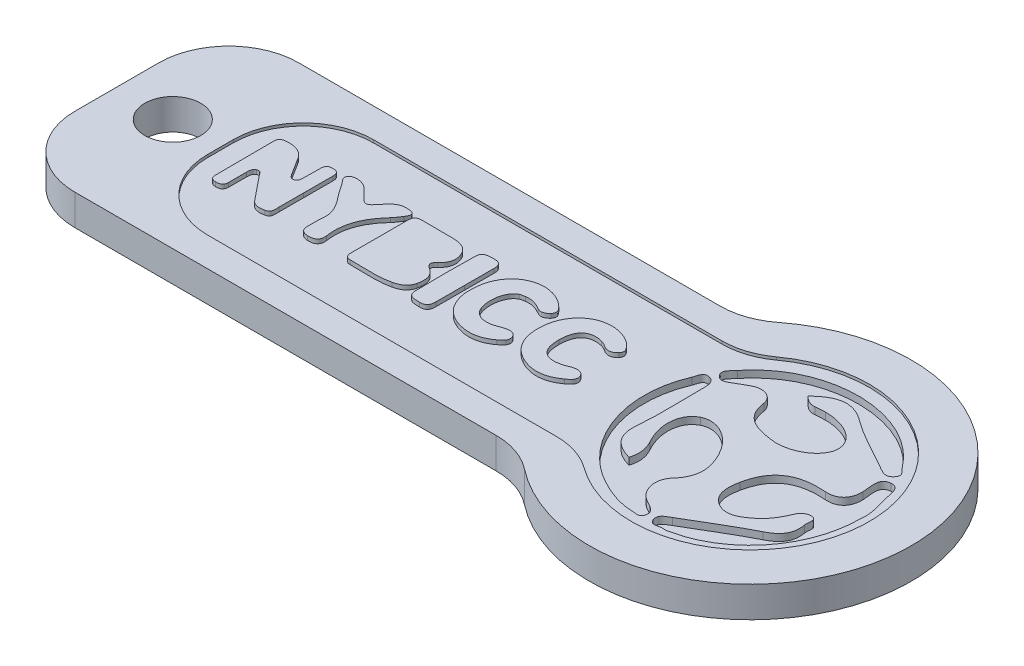
from build123d import *

# Parameters (mm, degrees)
ESQUISSE1_R             = 2
BOSS_EXTRU_1_DEPTH      = 2
ESQUISSE3_R             = 2
BOSS_EXTRU_2_DEPTH      = 0.2
CONG_1_R                = 5
BOSS_EXTRU_3_DEPTH      = 0.3
ENL_V_MAT_EXTRU_1_DEPTH = 0.5


with BuildPart() as part:
    # Esquisse1 → Boss.-Extru.1 (new body)
    with BuildSketch(Plane(origin=(0, 0, 0), x_dir=(1, 0, 0), z_dir=(0, 1, 0))):
        with BuildLine():
            Line((-18.5, 8), (18.5, 8))
            ThreePointArc((18.5, 8), (38.261355821, 0), (18.5, -8))
            Line((18.5, -8), (-18.5, -8))
            Line((-18.5, -8), (-18.5, 8))
        make_face()
        with Locations((-14.5, 0)):
            Circle(ESQUISSE1_R, mode=Mode.SUBTRACT)
    extrude(amount=BOSS_EXTRU_1_DEPTH)

    # Esquisse3 → Boss.-Extru.2 (add)
    with BuildSketch(Plane(origin=(0, 2, 0), x_dir=(1, 0, 0), z_dir=(0, 1, 0))):
        with BuildLine():
            Line((-18.5, -8), (18.5, -8))
            ThreePointArc((18.5, -8), (38.261355821, 0), (18.5, 8))
            Line((18.5, 8), (-18.5, 8))
            Line((-18.5, 8), (-18.5, -8))
        make_face()
        with Locations((-14.5, 0)):
            Circle(ESQUISSE3_R, mode=Mode.SUBTRACT)
        with BuildLine():
            Line((20.655136301, -5.913043478), (-11.087243835, -5.913043478))
            Line((-11.087243835, -5.913043478), (-11.087243835, 5.913043478))
            Line((-11.087243835, 5.913043478), (20.655136301, 5.913043478))
            ThreePointArc((20.655136301, 5.913043478), (35.261355821, 0), (20.655136301, -5.913043478))
        make_face(mode=Mode.SUBTRACT)
    extrude(amount=BOSS_EXTRU_2_DEPTH)

    # Congé1
    cong_1_edges = [part.edges().sort_by_distance(p)[0] for p in [
        (20.655136301, 2.1, -5.913043478),
        (-11.087243835, 2.1, -5.913043478),
        (-11.087243835, 2.1, 5.913043478),
        (20.655136301, 2.1, 5.913043478),
        (18.5, 1, 8),
        (-18.5, 1, 8),
        (-18.5, 1, -8),
        (18.5, 1, -8),
    ]]
    fillet(cong_1_edges, radius=CONG_1_R)

    # Esquisse4 → Boss.-Extru.3 (add)
    with BuildSketch(Plane(origin=(0, 2, 0), x_dir=(1, 0, 0), z_dir=(0, 1, 0))):
        with BuildLine():
            add(Edge.make_bspline(
                [(-5.179399212, -1.733733576), (-5.181960296, -2.003038068), (-5.100765252, -2.340580256), (-5.46884511, -2.427223029)],
                knots=[1, 1, 1, 1, 2, 2, 2, 2], degree=3))
            add(Edge.make_bspline(
                [(-5.46884511, -2.427223029), (-5.824206365, -2.510827228), (-6.192264519, -2.520550666), (-6.463544084, -2.180664435)],
                knots=[2, 2, 2, 2, 3, 3, 3, 3], degree=3))
            add(Edge.make_bspline(
                [(-6.463544084, -2.180664435), (-6.917159807, -1.612277424), (-7.37596281, -1.0480576), (-7.83687111, -0.48566092)],
                knots=[3, 3, 3, 3, 4, 4, 4, 4], degree=3))
            add(Edge.make_bspline(
                [(-7.83687111, -0.48566092), (-7.953031462, -0.343802912), (-8.052892033, -0.118080256), (-8.285820451, -0.219047737)],
                knots=[4, 4, 4, 4, 5, 5, 5, 5], degree=3))
            add(Edge.make_bspline(
                [(-8.285820451, -0.219047737), (-8.482068937, -0.304214631), (-8.503230436, -0.51778299), (-8.503599406, -0.717026643)],
                knots=[5, 5, 5, 5, 6, 6, 6, 6], degree=3))
            add(Edge.make_bspline(
                [(-8.503599406, -0.717026643), (-8.504337346, -1.145205158), (-8.510132341, -1.573296857), (-8.50689843, -2.001388557)],
                knots=[6, 6, 6, 6, 7, 7, 7, 7], degree=3))
            add(Edge.make_bspline(
                [(-8.50689843, -2.001388557), (-8.512042114, -2.334299424), (-8.69381371, -2.444124348), (-9.002103481, -2.437008874)],
                knots=[7, 7, 7, 7, 8, 8, 8, 8], degree=3))
            add(Edge.make_bspline(
                [(-9.002103481, -2.437008874), (-9.296330826, -2.430134949), (-9.435696319, -2.290063772), (-9.429062297, -2.001388557)],
                knots=[8, 8, 8, 8, 9, 9, 9, 9], degree=3))
            add(Edge.make_bspline(
                [(-9.429062297, -2.001388557), (-9.437185031, -0.610092066), (-9.444070539, 0.781188921), (-9.450826151, 2.172535671)],
                knots=[9, 9, 9, 9, 10, 10, 10, 10], degree=3))
            add(Edge.make_bspline(
                [(-9.450826151, 2.172535671), (-9.436859715, 2.458341505), (-9.289908617, 2.578171994), (-8.999299382, 2.591438078)],
                knots=[10, 10, 10, 10, 11, 11, 11, 11], degree=3))
            add(Edge.make_bspline(
                [(-8.999299382, 2.591438078), (-8.346765568, 2.653424992), (-7.822307658, 2.477925627), (-7.472394133, 1.887704289)],
                knots=[11, 11, 11, 11, 12, 12, 12, 12], degree=3))
            add(Edge.make_bspline(
                [(-7.472394133, 1.887704289), (-7.244153801, 1.502760344), (-6.998007585, 1.128451409), (-6.756289006, 0.751624797)],
                knots=[12, 12, 12, 12, 13, 13, 13, 13], degree=3))
            add(Edge.make_bspline(
                [(-6.756289006, 0.751624797), (-6.662983074, 0.606077092), (-6.556068669, 0.448809172), (-6.356651384, 0.487399065)],
                knots=[13, 13, 13, 13, 14, 14, 14, 14], degree=3))
            add(Edge.make_bspline(
                [(-6.356651384, 0.487399065), (-6.14538366, 0.528202776), (-6.124157048, 0.736735784), (-6.114021233, 0.896043889)],
                knots=[14, 14, 14, 14, 15, 15, 15, 15], degree=3))
            add(Edge.make_bspline(
                [(-6.114021233, 0.896043889), (-6.088345281, 1.301259465), (-6.08765075, 1.70868886), (-6.093923235, 2.115033049)],
                knots=[15, 15, 15, 15, 16, 16, 16, 16], degree=3))
            add(Edge.make_bspline(
                [(-6.093923235, 2.115033049), (-6.09887177, 2.434517424), (-5.970882683, 2.59017924), (-5.639895134, 2.586749992)],
                knots=[16, 16, 16, 16, 17, 17, 17, 17], degree=3))
            add(Edge.make_bspline(
                [(-5.639895134, 2.586749992), (-5.319586004, 2.583450969), (-5.169827703, 2.441245695), (-5.172236858, 2.119721135)],
                knots=[17, 17, 17, 17, 18, 18, 18, 18], degree=3))
            add(Edge.make_bspline(
                [(-5.172236858, 2.119721135), (-5.177489251, 1.413252629), (-5.175383953, 0.706784123), (-5.176035076, 0.000337322)],
                knots=[18, 18, 18, 18, 19, 19, 19, 19], degree=3))
            add(Edge.make_bspline(
                [(-5.176035076, 0.000337322), (-5.176577678, -0.577686311), (-5.174038299, -1.155709943), (-5.179399212, -1.733733576)],
                knots=[0, 0, 0, 0, 1, 1, 1, 1], degree=3))
        make_face()
        with BuildLine():
            add(Edge.make_bspline(
                [(-1.589367181, 2.219733635), (-1.281017011, 2.609539299), (-0.947468378, 2.794154387), (-0.444757978, 2.762336174)],
                knots=[6, 6, 6, 6, 7, 7, 7, 7], degree=3))
            add(Edge.make_bspline(
                [(-0.444757978, 2.762336174), (0.058516729, 2.730474553), (0.108284234, 2.532663371), (-0.136386103, 2.15896215)],
                knots=[7, 7, 7, 7, 8, 8, 8, 8], degree=3))
            add(Edge.make_bspline(
                [(-0.136386103, 2.15896215), (-0.2649612, 1.962540031), (-0.392038715, 1.760474846), (-0.54991435, 1.58862177)],
                knots=[8, 8, 8, 8, 9, 9, 9, 9], degree=3))
            add(Edge.make_bspline(
                [(-0.54991435, 1.58862177), (-1.432381415, 0.627911418), (-1.908916669, -0.461873225), (-1.708349066, -1.796415021)],
                knots=[9, 9, 9, 9, 10, 10, 10, 10], degree=3))
            add(Edge.make_bspline(
                [(-1.708349066, -1.796415021), (-1.634251263, -2.28927176), (-1.886018841, -2.497110236), (-2.382717206, -2.479226056)],
                knots=[10, 10, 10, 10, 11, 11, 11, 11], degree=3))
            add(Edge.make_bspline(
                [(-2.382717206, -2.479226056), (-2.788779242, -2.464727717), (-2.969248846, -2.276075666), (-2.971549481, -1.886704084)],
                knots=[11, 11, 11, 11, 12, 12, 12, 12], degree=3))
            add(Edge.make_bspline(
                [(-2.971549481, -1.886704084), (-2.973047064, -1.629553889), (-2.971223919, -1.372403693), (-2.970746429, -0.986504768)],
                knots=[12, 12, 12, 12, 13, 13, 13, 13], degree=3))
            add(Edge.make_bspline(
                [(-2.970746429, -0.986504768), (-2.823245355, -0.33008592), (-3.134872845, 0.302523528), (-3.613448284, 0.892006926)],
                knots=[0, 0, 0, 0, 1, 1, 1, 1], degree=3))
            add(Edge.make_bspline(
                [(-3.613448284, 0.892006926), (-3.869122601, 1.206759807), (-4.098122576, 1.545083342), (-4.318028533, 1.886402043)],
                knots=[1, 1, 1, 1, 2, 2, 2, 2], degree=3))
            add(Edge.make_bspline(
                [(-4.318028533, 1.886402043), (-4.469436346, 2.121457463), (-4.860023357, 2.376827922), (-4.596861126, 2.643701555)],
                knots=[2, 2, 2, 2, 3, 3, 3, 3], degree=3))
            add(Edge.make_bspline(
                [(-4.596861126, 2.643701555), (-4.345202068, 2.899028605), (-3.899009149, 2.823845598), (-3.56897658, 2.659198283)],
                knots=[3, 3, 3, 3, 4, 4, 4, 4], degree=3))
            add(Edge.make_bspline(
                [(-3.56897658, 2.659198283), (-3.348159051, 2.549028264), (-3.169534295, 2.340278215), (-2.994620941, 2.154404289)],
                knots=[4, 4, 4, 4, 5, 5, 5, 5], degree=3))
            add(Edge.make_bspline(
                [(-2.994620941, 2.154404289), (-2.27463078, 1.389421526), (-2.259850287, 1.372145061), (-1.589367181, 2.219733635)],
                knots=[5, 5, 5, 5, 6, 6, 6, 6], degree=3))
        make_face()
        with BuildLine():
            add(Edge.make_bspline(
                [(0.62837962, -2.452660236), (0.281265924, -2.464380451), (0.223381085, -2.208879767), (0.224987188, -1.924556037)],
                knots=[9, 9, 9, 9, 10, 10, 10, 10], degree=3))
            add(Edge.make_bspline(
                [(0.224987188, -1.924556037), (0.228633477, -1.260931428), (0.227504864, -0.597480451), (0.228286212, 0.066144158)],
                knots=[10, 10, 10, 10, 11, 11, 11, 11], degree=3))
            add(Edge.make_bspline(
                [(0.228286212, 0.066144158), (0.229089264, 0.708216594), (0.242979889, 1.350658), (0.225898761, 1.992318059)],
                knots=[0, 0, 0, 0, 1, 1, 1, 1], degree=3))
            add(Edge.make_bspline(
                [(0.225898761, 1.992318059), (0.215025006, 2.398445207), (0.360594415, 2.577200187), (0.785321978, 2.564611809)],
                knots=[1, 1, 1, 1, 2, 2, 2, 2], degree=3))
            add(Edge.make_bspline(
                [(0.785321978, 2.564611809), (1.533831329, 2.542517033), (2.284445977, 2.579500822), (3.0322825, 2.547595793)],
                knots=[2, 2, 2, 2, 3, 3, 3, 3], degree=3))
            add(Edge.make_bspline(
                [(3.0322825, 2.547595793), (3.534493706, 2.526108732), (4.016064311, 2.387332707), (4.239442925, 1.857622404)],
                knots=[3, 3, 3, 3, 4, 4, 4, 4], degree=3))
            add(Edge.make_bspline(
                [(4.239442925, 1.857622404), (4.454530571, 1.347402385), (4.356862114, 0.893482805), (3.934131328, 0.525902141)],
                knots=[4, 4, 4, 4, 5, 5, 5, 5], degree=3))
            add(Edge.make_bspline(
                [(3.934131328, 0.525902141), (3.614907402, 0.248284978), (3.681842852, 0.030896697), (4.013221074, -0.175031819)],
                knots=[5, 5, 5, 5, 6, 6, 6, 6], degree=3))
            add(Edge.make_bspline(
                [(4.013221074, -0.175031819), (4.531905693, -0.497294319), (4.592156279, -0.987720197), (4.468290971, -1.524940119)],
                knots=[6, 6, 6, 6, 7, 7, 7, 7], degree=3))
            add(Edge.make_bspline(
                [(4.468290971, -1.524940119), (4.352282549, -2.028041193), (3.970333769, -2.237963263), (3.506690752, -2.346831037)],
                knots=[7, 7, 7, 7, 8, 8, 8, 8], degree=3))
            add(Edge.make_bspline(
                [(3.506690752, -2.346831037), (2.554206255, -2.570817365), (1.587874542, -2.420624982), (0.62837962, -2.452660236)],
                knots=[8, 8, 8, 8, 9, 9, 9, 9], degree=3))
        make_face()
        with BuildLine():
            add(Edge.make_bspline(
                [(5.71134998, 2.74358383), (6.112572001, 2.753958391), (6.29946602, 2.567172893), (6.295667802, 2.165603606)],
                knots=[5, 5, 5, 5, 6, 6, 6, 6], degree=3))
            add(Edge.make_bspline(
                [(6.295667802, 2.165603606), (6.288896122, 1.461392326), (6.292281962, 0.757094231), (6.291652543, 0.052861248)],
                knots=[6, 6, 6, 6, 7, 7, 7, 7], degree=3))
            add(Edge.make_bspline(
                [(6.291652543, 0.052861248), (6.291109941, -0.630036604), (6.28883101, -1.313021272), (6.289894511, -1.995919123)],
                knots=[0, 0, 0, 0, 1, 1, 1, 1], degree=3))
            add(Edge.make_bspline(
                [(6.289894511, -1.995919123), (6.29052393, -2.36896922), (6.171889311, -2.60476258), (5.736548442, -2.599119513)],
                knots=[1, 1, 1, 1, 2, 2, 2, 2], degree=3))
            add(Edge.make_bspline(
                [(5.736548442, -2.599119513), (5.332526591, -2.593823713), (4.886789458, -2.605978009), (4.874591753, -2.082561896)],
                knots=[2, 2, 2, 2, 3, 3, 3, 3], degree=3))
            add(Edge.make_bspline(
                [(4.874591753, -2.082561896), (4.840841875, -0.632814729), (4.839561333, 0.818820696), (4.877825664, 2.268437639)],
                knots=[3, 3, 3, 3, 4, 4, 4, 4], degree=3))
            add(Edge.make_bspline(
                [(4.877825664, 2.268437639), (4.890761308, 2.75808217), (5.342445366, 2.733990617), (5.71134998, 2.74358383)],
                knots=[4, 4, 4, 4, 5, 5, 5, 5], degree=3))
        make_face()
        with BuildLine():
            add(Edge.make_bspline(
                [(10.814266409, -2.164256135), (10.026320706, -2.763028888), (9.152687211, -2.818244123), (8.265510355, -2.456393342)],
                knots=[11, 11, 11, 11, 12, 12, 12, 12], degree=3))
            add(Edge.make_bspline(
                [(8.265510355, -2.456393342), (7.376488651, -2.093934846), (6.922395439, -1.369799201), (6.788329203, -0.437217365)],
                knots=[12, 12, 12, 12, 13, 13, 13, 13], degree=3))
            add(Edge.make_bspline(
                [(6.788329203, -0.437217365), (6.764150834, -0.269488069), (6.785290629, -0.095334358), (6.78550767, 0.075867595)],
                knots=[13, 13, 13, 13, 14, 14, 14, 14], degree=3))
            add(Edge.make_bspline(
                [(6.78550767, 0.075867595), (6.771248075, 2.16234799), (8.614078226, 3.420882023), (10.381312991, 2.533401311)],
                knots=[0, 0, 0, 0, 1, 1, 1, 1], degree=3))
            add(Edge.make_bspline(
                [(10.381312991, 2.533401311), (10.606167484, 2.420539982), (10.818694046, 2.259582365), (10.994670901, 2.079655363)],
                knots=[1, 1, 1, 1, 2, 2, 2, 2], degree=3))
            add(Edge.make_bspline(
                [(10.994670901, 2.079655363), (11.171602737, 1.898773381), (11.349142288, 1.656078117), (11.115866605, 1.405091887)],
                knots=[2, 2, 2, 2, 3, 3, 3, 3], degree=3))
            add(Edge.make_bspline(
                [(11.115866605, 1.405091887), (10.92079014, 1.195256633), (10.666070804, 1.062210491), (10.371415921, 1.236494426)],
                knots=[3, 3, 3, 3, 4, 4, 4, 4], degree=3))
            add(Edge.make_bspline(
                [(10.371415921, 1.236494426), (9.994372269, 1.459438957), (9.60274346, 1.610412688), (9.155031253, 1.532798821)],
                knots=[4, 4, 4, 4, 5, 5, 5, 5], degree=3))
            add(Edge.make_bspline(
                [(9.155031253, 1.532798821), (9.030189261, 1.511181535), (8.896578812, 1.499808586), (8.785714261, 1.445461516)],
                knots=[5, 5, 5, 5, 6, 6, 6, 6], degree=3))
            add(Edge.make_bspline(
                [(8.785714261, 1.445461516), (8.229481547, 1.172944817), (7.985679374, 0.128825603), (8.273063383, -0.709039533)],
                knots=[6, 6, 6, 6, 7, 7, 7, 7], degree=3))
            add(Edge.make_bspline(
                [(8.273063383, -0.709039533), (8.464406742, -1.266574494), (8.99520225, -1.533795393), (9.677839652, -1.395757307)],
                knots=[7, 7, 7, 7, 8, 8, 8, 8], degree=3))
            add(Edge.make_bspline(
                [(9.677839652, -1.395757307), (9.884636331, -1.353911799), (10.079539163, -1.255635627), (10.283123636, -1.193909162)],
                knots=[8, 8, 8, 8, 9, 9, 9, 9], degree=3))
            add(Edge.make_bspline(
                [(10.283123636, -1.193909162), (10.603736624, -1.096761604), (10.959423441, -1.04128592), (11.153110843, -1.367455158)],
                knots=[9, 9, 9, 9, 10, 10, 10, 10], degree=3))
            add(Edge.make_bspline(
                [(11.153110843, -1.367455158), (11.365724222, -1.72565965), (11.071329788, -1.969006037), (10.814266409, -2.164256135)],
                knots=[10, 10, 10, 10, 11, 11, 11, 11], degree=3))
        make_face()
        with BuildLine():
            add(Edge.make_bspline(
                [(15.114890725, 1.26128051), (14.952891311, 1.359166008), (14.782731154, 1.465255656), (14.602153029, 1.507057756)],
                knots=[10, 10, 10, 10, 11, 11, 11, 11], degree=3))
            add(Edge.make_bspline(
                [(14.602153029, 1.507057756), (13.592825491, 1.74081093), (13.041367678, 1.232934953), (13.029387014, 0.077256658)],
                knots=[11, 11, 11, 11, 12, 12, 12, 12], degree=3))
            add(Edge.make_bspline(
                [(13.029387014, 0.077256658), (13.015670022, -1.229069807), (13.68320137, -1.713244904), (14.918772463, -1.291924885)],
                knots=[0, 0, 0, 0, 1, 1, 1, 1], degree=3))
            add(Edge.make_bspline(
                [(14.918772463, -1.291924885), (14.999251272, -1.2644909), (15.073566115, -1.21908592), (15.154305373, -1.192867365)],
                knots=[1, 1, 1, 1, 2, 2, 2, 2], degree=3))
            add(Edge.make_bspline(
                [(15.154305373, -1.192867365), (15.480214162, -1.086864533), (15.829563381, -1.064379084), (16.010315138, -1.39132967)],
                knots=[2, 2, 2, 2, 3, 3, 3, 3], degree=3))
            add(Edge.make_bspline(
                [(16.010315138, -1.39132967), (16.211642385, -1.755524494), (15.90327051, -1.991231037), (15.64646758, -2.177799494)],
                knots=[3, 3, 3, 3, 4, 4, 4, 4], degree=3))
            add(Edge.make_bspline(
                [(15.64646758, -2.177799494), (14.786290627, -2.80261717), (13.856313284, -2.846893537), (12.931110842, -2.370358283)],
                knots=[4, 4, 4, 4, 5, 5, 5, 5], degree=3))
            add(Edge.make_bspline(
                [(12.931110842, -2.370358283), (11.898863772, -1.838694611), (11.535276663, -0.87893924), (11.587974222, 0.202966814)],
                knots=[5, 5, 5, 5, 6, 6, 6, 6], degree=3))
            add(Edge.make_bspline(
                [(11.587974222, 0.202966814), (11.685642679, 2.205061662), (13.445584866, 3.336062394), (15.162379299, 2.559229191)],
                knots=[6, 6, 6, 6, 7, 7, 7, 7], degree=3))
            add(Edge.make_bspline(
                [(15.162379299, 2.559229191), (15.399301271, 2.45201093), (15.613390529, 2.315839397), (15.790235549, 2.126970305)],
                knots=[7, 7, 7, 7, 8, 8, 8, 8], degree=3))
            add(Edge.make_bspline(
                [(15.790235549, 2.126970305), (15.982794338, 1.921519279), (16.213986427, 1.683034612), (15.977932619, 1.407870012)],
                knots=[8, 8, 8, 8, 9, 9, 9, 9], degree=3))
            add(Edge.make_bspline(
                [(15.977932619, 1.407870012), (15.760023439, 1.153888616), (15.450522951, 1.05834716), (15.114890725, 1.26128051)],
                knots=[9, 9, 9, 9, 10, 10, 10, 10], degree=3))
        make_face()
    extrude(amount=BOSS_EXTRU_3_DEPTH)

    # Esquisse5 → Enlèv. mat.-Extru.1 (cut)
    with BuildSketch(Plane(origin=(0, 2, 0), x_dir=(1, 0, 0), z_dir=(0, 1, 0))):
        with BuildLine():
            add(Edge.make_bspline(
                [(23.186663146, -6.769797032), (19.809617805, -4.933230685), (18.300149632, -0.679304914), (19.787679299, 2.792463637)],
                knots=[9, 9, 9, 9, 10, 10, 10, 10], degree=3))
            add(Edge.make_bspline(
                [(19.787679299, 2.792463637), (19.903969875, 3.063808315), (19.90182551, 3.526413876), (20.358905207, 3.437257768)],
                knots=[10, 10, 10, 10, 11, 11, 11, 11], degree=3))
            add(Edge.make_bspline(
                [(20.358905207, 3.437257768), (20.775736818, 3.356019316), (20.87586218, 3.003106284), (20.870748693, 2.587676757)],
                knots=[11, 11, 11, 11, 12, 12, 12, 12], degree=3))
            add(Edge.make_bspline(
                [(20.870748693, 2.587676757), (20.851779309, 1.040022388), (20.974997834, -0.519467229), (20.824727316, -2.052853322)],
                knots=[12, 12, 12, 12, 13, 13, 13, 13], degree=3))
            add(Edge.make_bspline(
                [(20.824727316, -2.052853322), (20.689962209, -3.427226486), (21.291704084, -4.053216183), (22.495847638, -4.410995275)],
                knots=[13, 13, 13, 13, 14, 14, 14, 14], degree=3))
            add(Edge.make_bspline(
                [(22.495847638, -4.410995275), (22.689500314, -3.765376388), (22.587395539, -3.237532638), (22.270524338, -2.661688097)],
                knots=[0, 0, 0, 0, 1, 1, 1, 1], degree=3))
            add(Edge.make_bspline(
                [(22.270524338, -2.661688097), (21.485191808, -1.2333759), (21.653277053, 0.156172771), (22.576508761, 0.620386606)],
                knots=[1, 1, 1, 1, 2, 2, 2, 2], degree=3))
            add(Edge.make_bspline(
                [(22.576508761, 0.620386606), (23.507658126, 1.088518032), (24.876752853, 0.314154756), (25.561795069, -1.087229162)],
                knots=[2, 2, 2, 2, 3, 3, 3, 3], degree=3))
            add(Edge.make_bspline(
                [(25.561795069, -1.087229162), (26.074133409, -2.134999006), (26.251950772, -3.132623693), (25.35082252, -4.130743234)],
                knots=[3, 3, 3, 3, 4, 4, 4, 4], degree=3))
            add(Edge.make_bspline(
                [(25.35082252, -4.130743234), (24.736379405, -4.811166818), (24.985950528, -5.909246768), (25.740107286, -6.388759825)],
                knots=[4, 4, 4, 4, 5, 5, 5, 5], degree=3))
            add(Edge.make_bspline(
                [(25.740107286, -6.388759825), (25.911656505, -6.49779255), (26.091783184, -6.593464229), (26.267951036, -6.695239102)],
                knots=[5, 5, 5, 5, 6, 6, 6, 6], degree=3))
            add(Edge.make_bspline(
                [(26.267951036, -6.695239102), (26.529893497, -6.846664278), (26.743505264, -7.040811807), (26.661194629, -7.375167833)],
                knots=[6, 6, 6, 6, 7, 7, 7, 7], degree=3))
            add(Edge.make_bspline(
                [(26.661194629, -7.375167833), (26.55991461, -7.786391104), (26.214012003, -7.63529583), (25.956688175, -7.628862735)],
                knots=[7, 7, 7, 7, 8, 8, 8, 8], degree=3))
            add(Edge.make_bspline(
                [(25.956688175, -7.628862735), (24.954939708, -7.603295303), (24.048368068, -7.23825836), (23.186663146, -6.769797032)],
                knots=[8, 8, 8, 8, 9, 9, 9, 9], degree=3))
        make_face()
        with BuildLine():
            add(Edge.make_bspline(
                [(29.456952041, 3.520475634), (29.409446103, 2.504623842), (27.919937022, 1.549803984), (26.503501309, 1.757642461)],
                knots=[3, 3, 3, 3, 4, 4, 4, 4], degree=3))
            add(Edge.make_bspline(
                [(26.503501309, 1.757642461), (25.335811964, 1.929109204), (24.195669464, 2.169525537), (23.97545965, 3.74307724)],
                knots=[4, 4, 4, 4, 5, 5, 5, 5], degree=3))
            add(Edge.make_bspline(
                [(23.97545965, 3.74307724), (23.890674747, 4.347953188), (23.203983019, 4.748619584), (22.453125285, 4.37294329)],
                knots=[5, 5, 5, 5, 6, 6, 6, 6], degree=3))
            add(Edge.make_bspline(
                [(22.453125285, 4.37294329), (22.198935529, 4.245848412), (21.95414799, 4.098959394), (21.711174914, 3.950998192)],
                knots=[6, 6, 6, 6, 7, 7, 7, 7], degree=3))
            add(Edge.make_bspline(
                [(21.711174914, 3.950998192), (21.36015882, 3.737303949), (20.97582259, 3.449629106), (20.651198684, 3.911574862)],
                knots=[7, 7, 7, 7, 8, 8, 8, 8], degree=3))
            add(Edge.make_bspline(
                [(20.651198684, 3.911574862), (20.37061674, 4.311086601), (20.809056955, 4.578389975), (21.005183898, 4.828868329)],
                knots=[8, 8, 8, 8, 9, 9, 9, 9], degree=3))
            add(Edge.make_bspline(
                [(21.005183898, 4.828868329), (23.928283614, 8.56352781), (30.092343955, 8.488392552), (32.918122479, 4.687917553)],
                knots=[9, 9, 9, 9, 10, 10, 10, 10], degree=3))
            add(Edge.make_bspline(
                [(32.918122479, 4.687917553), (33.085218016, 4.463171581), (33.509967284, 4.24906496), (33.194745595, 3.874873227)],
                knots=[10, 10, 10, 10, 11, 11, 11, 11], degree=3))
            add(Edge.make_bspline(
                [(33.194745595, 3.874873227), (32.899647948, 3.524434462), (32.5761787, 3.664642958), (32.22565746, 3.874130946)],
                knots=[11, 11, 11, 11, 12, 12, 12, 12], degree=3))
            add(Edge.make_bspline(
                [(32.22565746, 3.874130946), (30.969719238, 4.624658778), (29.615800019, 5.237122479), (28.44893543, 6.103610985)],
                knots=[12, 12, 12, 12, 13, 13, 13, 13], degree=3))
            add(Edge.make_bspline(
                [(28.44893543, 6.103610985), (27.188048672, 7.040038787), (26.193393106, 6.833107542), (25.100591593, 5.772636459)],
                knots=[13, 13, 13, 13, 14, 14, 14, 14], degree=3))
            add(Edge.make_bspline(
                [(25.100591593, 5.772636459), (25.3971738, 5.479930604), (25.666374112, 5.331886927), (26.013596329, 5.360258529)],
                knots=[0, 0, 0, 0, 1, 1, 1, 1], degree=3))
            add(Edge.make_bspline(
                [(26.013596329, 5.360258529), (26.256899307, 5.380217621), (26.50086209, 5.404218016), (26.744494971, 5.402403553)],
                knots=[1, 1, 1, 1, 2, 2, 2, 2], degree=3))
            add(Edge.make_bspline(
                [(26.744494971, 5.402403553), (28.303283545, 5.391021923), (29.505447685, 4.55381225), (29.456952041, 3.520475634)],
                knots=[2, 2, 2, 2, 3, 3, 3, 3], degree=3))
        make_face()
        with BuildLine():
            add(Edge.make_bspline(
                [(28.008680752, -2.001388557), (28.386418936, -0.107419202), (29.587098515, 0.635397163), (31.650307773, 0.477786318)],
                knots=[11, 11, 11, 11, 12, 12, 12, 12], degree=3))
            add(Edge.make_bspline(
                [(31.650307773, 0.477786318), (32.417990526, 0.419063701), (33.010660087, 0.836142739), (32.989876239, 1.811746445)],
                knots=[12, 12, 12, 12, 13, 13, 13, 13], degree=3))
            add(Edge.make_bspline(
                [(32.989876239, 1.811746445), (32.978164706, 2.360538994), (32.650406728, 3.276925229), (33.476812098, 3.344967587)],
                knots=[13, 13, 13, 13, 14, 14, 14, 14], degree=3))
            add(Edge.make_bspline(
                [(33.476812098, 3.344967587), (34.182473212, 3.403277826), (34.110719452, 2.450684809), (34.290846131, 1.919624511)],
                knots=[14, 14, 14, 14, 15, 15, 15, 15], degree=3))
            add(Edge.make_bspline(
                [(34.290846131, 1.919624511), (34.511550799, 1.269222041), (34.657202684, 0.583272593), (34.572252831, 0.043016267)],
                knots=[15, 15, 15, 15, 16, 16, 16, 16], degree=3))
            add(Edge.make_bspline(
                [(34.572252831, 0.043016267), (34.557242274, -3.684715265), (31.980540019, -6.861509883), (28.528111992, -7.568985459)],
                knots=[0, 0, 0, 0, 1, 1, 1, 1], degree=3))
            add(Edge.make_bspline(
                [(28.528111992, -7.568985459), (28.409347149, -7.593233282), (28.279365625, -7.630677198), (28.166703975, -7.606264424)],
                knots=[1, 1, 1, 1, 2, 2, 2, 2], degree=3))
            add(Edge.make_bspline(
                [(28.166703975, -7.606264424), (27.847688408, -7.537479786), (27.395062393, -7.903011582), (27.221038907, -7.385394805)],
                knots=[2, 2, 2, 2, 3, 3, 3, 3], degree=3))
            add(Edge.make_bspline(
                [(27.221038907, -7.385394805), (27.065984805, -6.923366573), (27.456754131, -6.765673253), (27.778408916, -6.581257842)],
                knots=[3, 3, 3, 3, 4, 4, 4, 4], degree=3))
            add(Edge.make_bspline(
                [(27.778408916, -6.581257842), (29.151792373, -5.793780948), (30.49004123, -4.937849317), (31.901363456, -4.226579865)],
                knots=[4, 4, 4, 4, 5, 5, 5, 5], degree=3))
            add(Edge.make_bspline(
                [(31.901363456, -4.226579865), (32.758779647, -3.794737697), (33.131239393, -3.238522345), (32.960349979, -2.315290637)],
                knots=[5, 5, 5, 5, 6, 6, 6, 6], degree=3))
            add(Edge.make_bspline(
                [(32.960349979, -2.315290637), (32.90839036, -2.033883937), (33.154827411, -1.581257922), (32.667231747, -1.528308596)],
                knots=[6, 6, 6, 6, 7, 7, 7, 7], degree=3))
            add(Edge.make_bspline(
                [(32.667231747, -1.528308596), (32.350195595, -1.493998752), (32.043386415, -1.733177951), (31.914889452, -2.047739836)],
                knots=[7, 7, 7, 7, 8, 8, 8, 8], degree=3))
            add(Edge.make_bspline(
                [(31.914889452, -2.047739836), (31.664328622, -2.660368488), (31.338550058, -3.217903449), (30.828521035, -3.640178449)],
                knots=[8, 8, 8, 8, 9, 9, 9, 9], degree=3))
            add(Edge.make_bspline(
                [(30.828521035, -3.640178449), (30.215067627, -4.148228058), (29.523757265, -4.58204964), (28.723249229, -4.145918742)],
                knots=[9, 9, 9, 9, 10, 10, 10, 10], degree=3))
            add(Edge.make_bspline(
                [(28.723249229, -4.145918742), (27.87045167, -3.681416242), (27.841750166, -2.838515754), (28.008680752, -2.001388557)],
                knots=[10, 10, 10, 10, 11, 11, 11, 11], degree=3))
        make_face()
    extrude(amount=-ENL_V_MAT_EXTRU_1_DEPTH, mode=Mode.SUBTRACT)


solid = part.part
